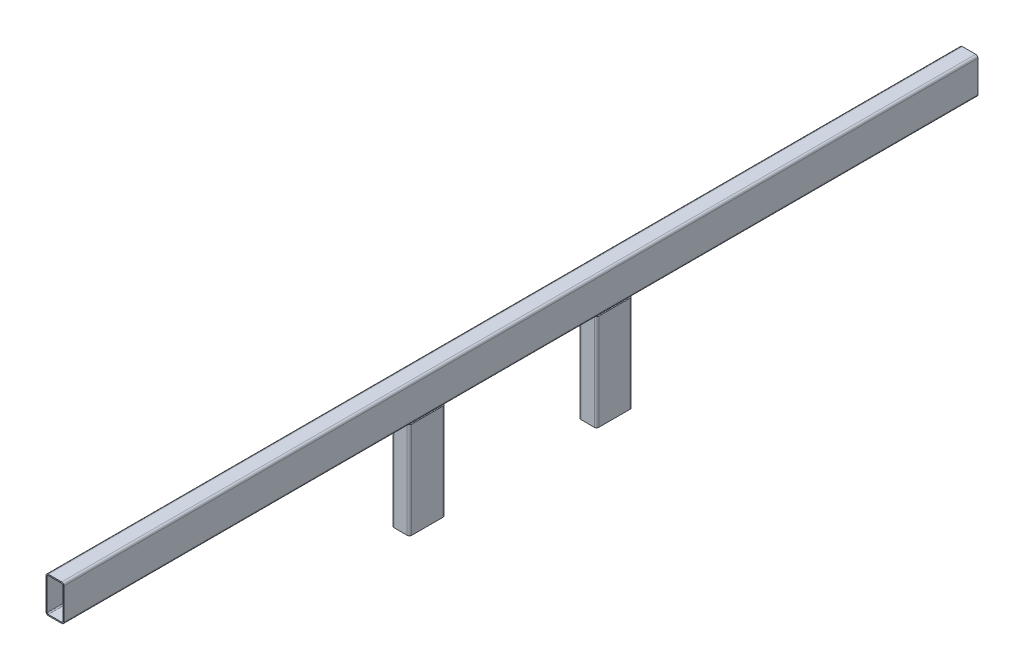
from build123d import *

# Parameters (mm, degrees)
STRUCTURAL_MEMBER1_DEPTH   = 2540
STRUCTURAL_MEMBER1_2_DEPTH = 318.811628174
STRUCTURAL_MEMBER1_3_DEPTH = 318.811628174


with BuildPart() as part:
    # Sketch11 → Structural Member1 (new body)
    with BuildSketch(Plane(origin=(0, 0, 1270), x_dir=(1, 0, 0), z_dir=(0, 0, -1))):
        with BuildLine():
            Line((-18.6, -50), (18.6, -50))
            ThreePointArc((18.6, -50), (23.1254834, -48.1254834), (25, -43.6))
            Line((25, -43.6), (25, 43.6))
            ThreePointArc((25, 43.6), (23.1254834, 48.1254834), (18.6, 50))
            Line((18.6, 50), (-18.6, 50))
            ThreePointArc((-18.6, 50), (-23.1254834, 48.1254834), (-25, 43.6))
            Line((-25, 43.6), (-25, -43.6))
            ThreePointArc((-25, -43.6), (-23.1254834, -48.1254834), (-18.6, -50))
        make_face()
        with BuildLine():
            Line((-18.6, -46.8), (18.6, -46.8))
            ThreePointArc((18.6, -46.8), (20.8627417, -45.8627417), (21.8, -43.6))
            Line((21.8, -43.6), (21.8, 43.6))
            ThreePointArc((21.8, 43.6), (20.8627417, 45.8627417), (18.6, 46.8))
            Line((18.6, 46.8), (-18.6, 46.8))
            ThreePointArc((-18.6, 46.8), (-20.8627417, 45.8627417), (-21.8, 43.6))
            Line((-21.8, 43.6), (-21.8, -43.6))
            ThreePointArc((-21.8, -43.6), (-20.8627417, -45.8627417), (-18.6, -46.8))
        make_face(mode=Mode.SUBTRACT)
    extrude(amount=STRUCTURAL_MEMBER1_DEPTH)


with BuildPart() as body_2:
    # Sketch11 on segment 2 (carried to segment 2) → Structural Member1 2 (new body)
    with BuildSketch(Plane(origin=(0, 1, 260), x_dir=(1, 0, 0), z_dir=(0, -1, 0))):
        with BuildLine():
            Line((-18.6, -50), (18.6, -50))
            ThreePointArc((18.6, -50), (23.1254834, -48.1254834), (25, -43.6))
            Line((25, -43.6), (25, 43.6))
            ThreePointArc((25, 43.6), (23.1254834, 48.1254834), (18.6, 50))
            Line((18.6, 50), (-18.6, 50))
            ThreePointArc((-18.6, 50), (-23.1254834, 48.1254834), (-25, 43.6))
            Line((-25, 43.6), (-25, -43.6))
            ThreePointArc((-25, -43.6), (-23.1254834, -48.1254834), (-18.6, -50))
        make_face()
        with BuildLine():
            Line((-18.6, -46.8), (18.6, -46.8))
            ThreePointArc((18.6, -46.8), (20.8627417, -45.8627417), (21.8, -43.6))
            Line((21.8, -43.6), (21.8, 43.6))
            ThreePointArc((21.8, 43.6), (20.8627417, 45.8627417), (18.6, 46.8))
            Line((18.6, 46.8), (-18.6, 46.8))
            ThreePointArc((-18.6, 46.8), (-20.8627417, 45.8627417), (-21.8, 43.6))
            Line((-21.8, 43.6), (-21.8, -43.6))
            ThreePointArc((-21.8, -43.6), (-20.8627417, -45.8627417), (-18.6, -46.8))
        make_face(mode=Mode.SUBTRACT)
    extrude(amount=STRUCTURAL_MEMBER1_2_DEPTH)

    # Structural Member1 2 end butt 1
    split(bisect_by=Plane(origin=(0, -50, 260), x_dir=(1, 0, 0), z_dir=(0, -1, 0)), keep=Keep.TOP)


with BuildPart() as body_3:
    # Sketch11 on segment 3 (carried to segment 3) → Structural Member1 3 (new body)
    with BuildSketch(Plane(origin=(0, 1, -260), x_dir=(1, 0, 0), z_dir=(0, -1, 0))):
        with BuildLine():
            Line((-18.6, -50), (18.6, -50))
            ThreePointArc((18.6, -50), (23.1254834, -48.1254834), (25, -43.6))
            Line((25, -43.6), (25, 43.6))
            ThreePointArc((25, 43.6), (23.1254834, 48.1254834), (18.6, 50))
            Line((18.6, 50), (-18.6, 50))
            ThreePointArc((-18.6, 50), (-23.1254834, 48.1254834), (-25, 43.6))
            Line((-25, 43.6), (-25, -43.6))
            ThreePointArc((-25, -43.6), (-23.1254834, -48.1254834), (-18.6, -50))
        make_face()
        with BuildLine():
            Line((-18.6, -46.8), (18.6, -46.8))
            ThreePointArc((18.6, -46.8), (20.8627417, -45.8627417), (21.8, -43.6))
            Line((21.8, -43.6), (21.8, 43.6))
            ThreePointArc((21.8, 43.6), (20.8627417, 45.8627417), (18.6, 46.8))
            Line((18.6, 46.8), (-18.6, 46.8))
            ThreePointArc((-18.6, 46.8), (-20.8627417, 45.8627417), (-21.8, 43.6))
            Line((-21.8, 43.6), (-21.8, -43.6))
            ThreePointArc((-21.8, -43.6), (-20.8627417, -45.8627417), (-18.6, -46.8))
        make_face(mode=Mode.SUBTRACT)
    extrude(amount=STRUCTURAL_MEMBER1_3_DEPTH)

    # Structural Member1 3 end butt 1
    split(bisect_by=Plane(origin=(0, -50, -260), x_dir=(1, 0, 0), z_dir=(0, -1, 0)), keep=Keep.TOP)


solid = Compound([part.part, body_2.part, body_3.part])
